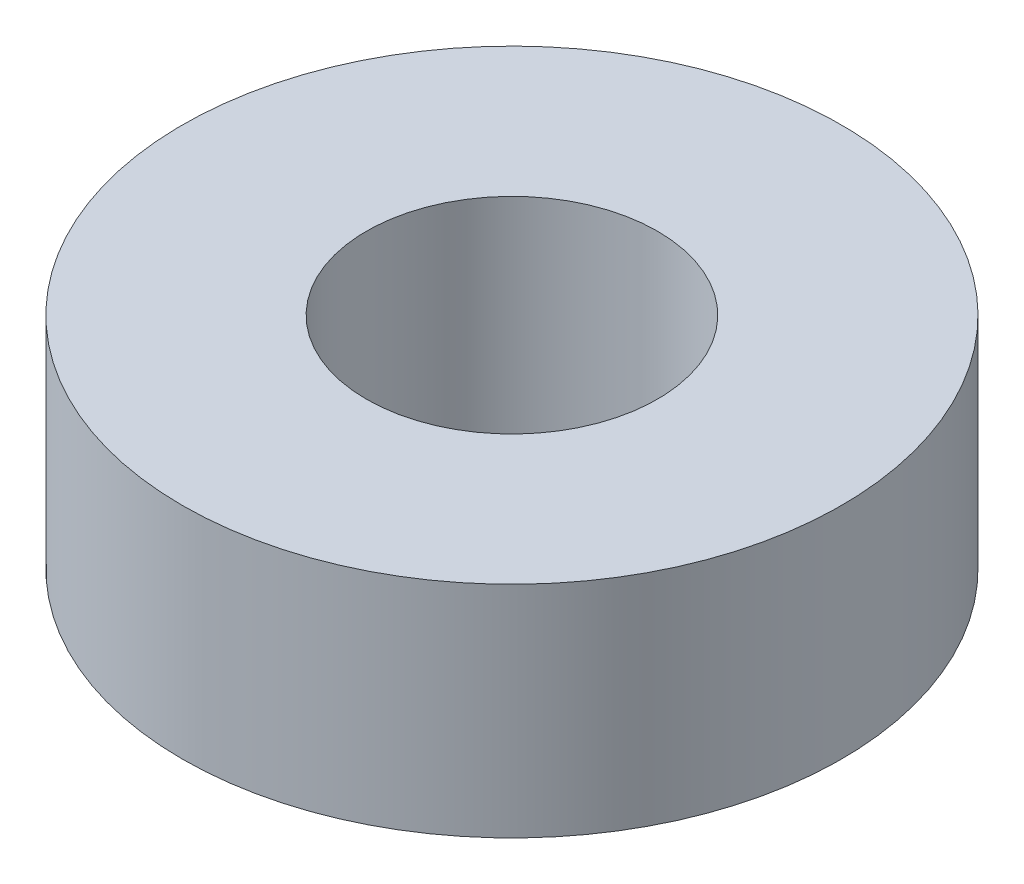
from build123d import *

# Parameters (mm, degrees)
SKETCH_1_R      = 6
SKETCH_1_R_2    = 2.65
EXTRUDE_1_DEPTH = 4


with BuildPart() as part:
    # 草图1 → 凸台-拉伸1 (new body)
    with BuildSketch(Plane(origin=(0, 0, 0), x_dir=(1, 0, 0), z_dir=(0, 1, 0))):
        Circle(SKETCH_1_R)
        Circle(SKETCH_1_R_2, mode=Mode.SUBTRACT)
    extrude(amount=EXTRUDE_1_DEPTH)


solid = part.part
